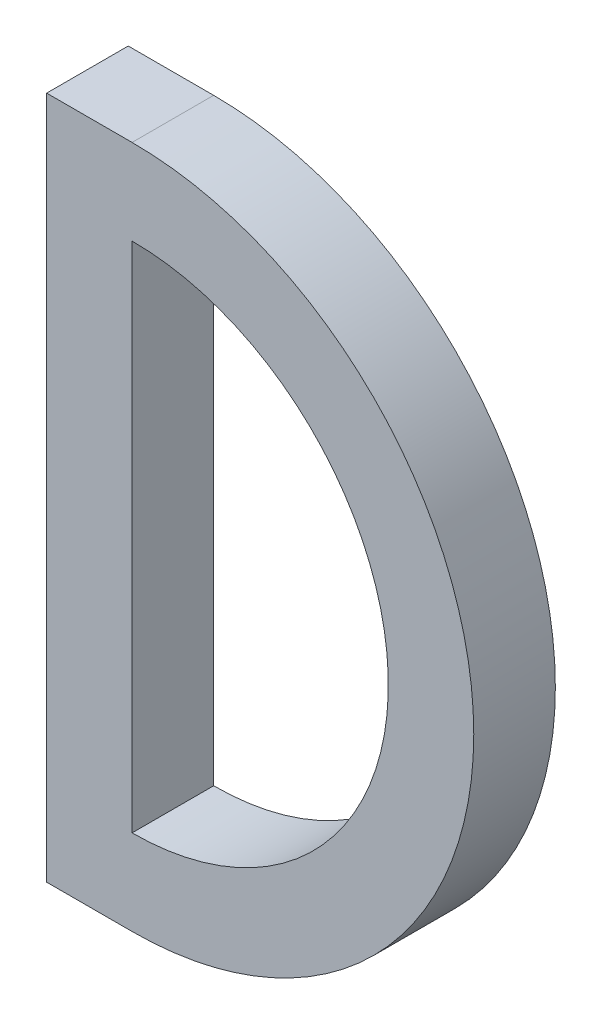
from build123d import *

# Parameters (mm, degrees)
SKETCH3_W           = 5
SKETCH3_H           = 40
BOSS_EXTRUDE1_DEPTH = 4.7752


with BuildPart() as part:
    # Sketch3 → Boss-Extrude1 (new body)
    with BuildSketch(Plane.XY):
        with Locations((-2.5, 20)):
            Rectangle(SKETCH3_W, SKETCH3_H)
        with BuildLine():
            Line((0, 5), (0, 0))
            ThreePointArc((0, 0), (20, 20), (0, 40))
            Line((0, 40), (0, 35))
            ThreePointArc((0, 35), (15, 20), (0, 5))
        make_face()
    extrude(amount=BOSS_EXTRUDE1_DEPTH)


solid = part.part
